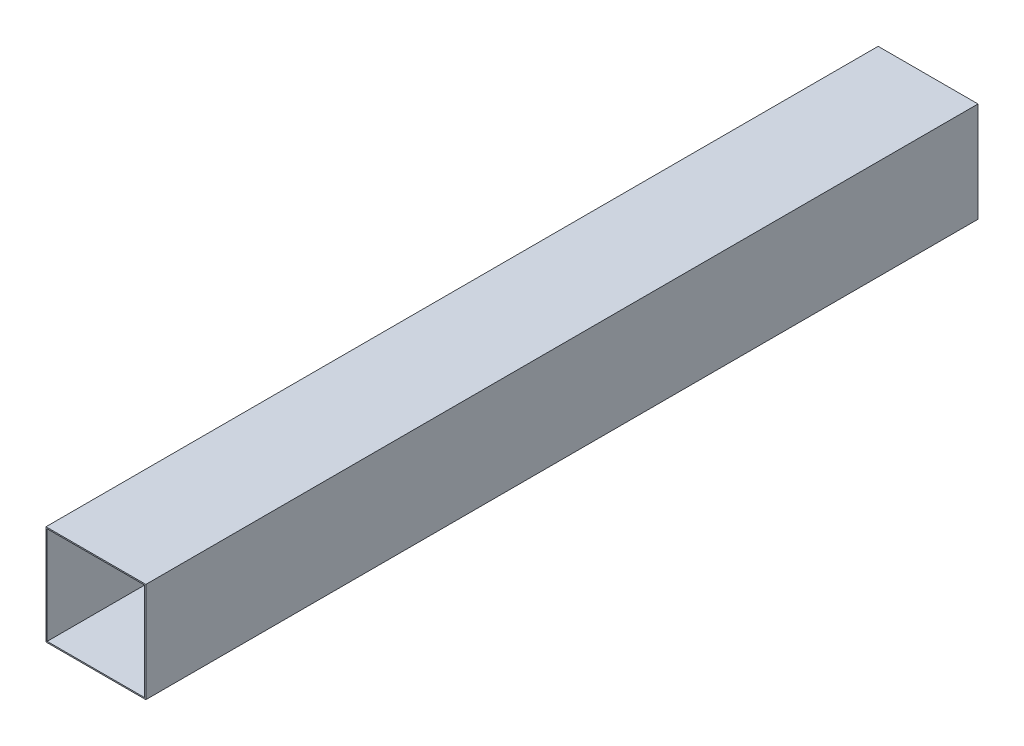
from build123d import *

# Parameters (mm, degrees)
SKETCH1_W           = 76.2
SKETCH1_H           = 76.2
SKETCH1_W_2         = 74.3712
SKETCH1_H_2         = 74.3712
BOSS_EXTRUDE1_DEPTH = 635


with BuildPart() as part:
    # Sketch1 → Boss-Extrude1 (new body)
    with BuildSketch(Plane.XY):
        Rectangle(SKETCH1_W, SKETCH1_H)
        Rectangle(SKETCH1_W_2, SKETCH1_H_2, mode=Mode.SUBTRACT)
    extrude(amount=BOSS_EXTRUDE1_DEPTH)


solid = part.part
